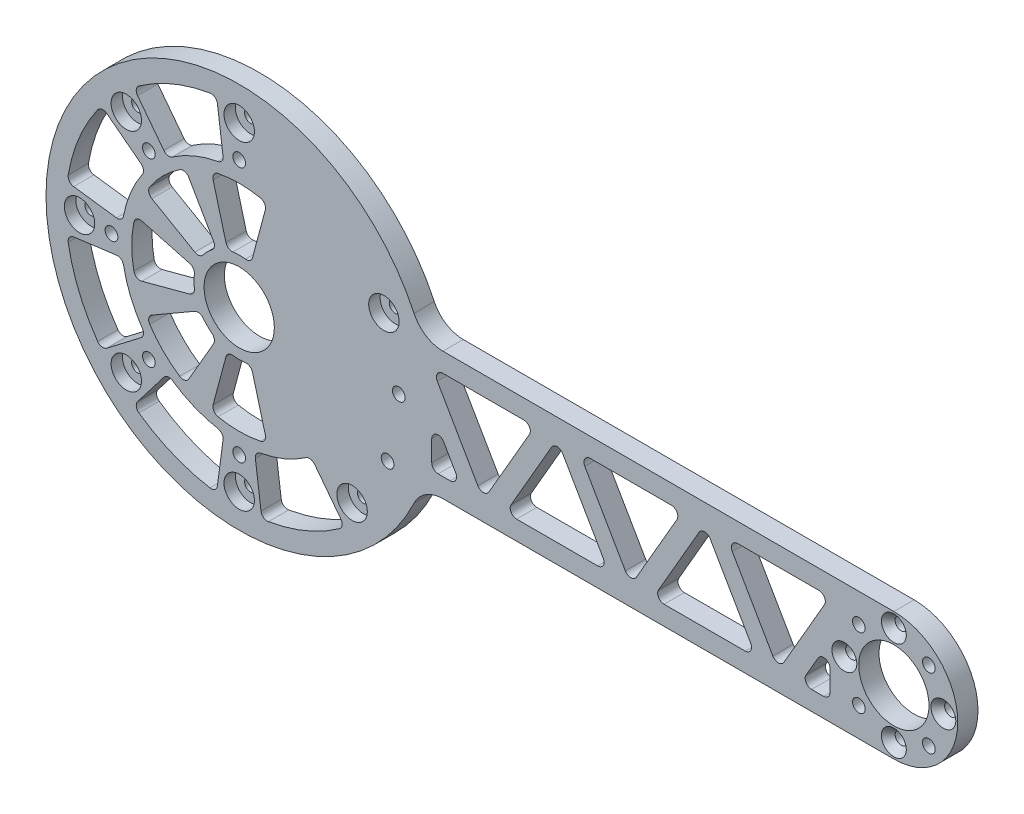
from build123d import *

# Parameters (mm, degrees)
SKETCH1_R                = 11
SKETCH1_R_2              = 1.89865
SKETCH1_R_3              = 1.9939
BOSS_EXTRUDE1_DEPTH      = 6.35
FILLET1_R                = 10
CUT_EXTRUDE1_DEPTH       = 7.35
FILLET2_R                = 2
CUT_EXTRUDE2_DEPTH       = 7.35
FILLET3_R                = 2
CIRPATTERN1_COUNT        = 8
FILLET3_OF_CIRPATTERN1_R = 2
CUT_EXTRUDE4_DEPTH       = 7.35
FILLET5_R                = 2
CIRPATTERN3_COUNT        = 8
FILLET5_OF_CIRPATTERN3_R = 2
CHAMFER1_SIZE            = 2.301024407
CHAMFER1_SIZE2           = 2.00025
CHAMFER1_PART_2_SIZE     = 2.301024407
CHAMFER1_PART_2_SIZE2    = 2.00025
CHAMFER1_PART_3_SIZE     = 2.301024407
CHAMFER1_PART_3_SIZE2    = 2.00025
CHAMFER1_PART_4_SIZE     = 2.301024407
CHAMFER1_PART_4_SIZE2    = 2.00025
SKETCH6_R                = 4.7625
SKETCH6_R_2              = 1.89865
CUT_EXTRUDE5_DEPTH       = 3.571875


with BuildPart() as part:
    # Sketch1 → Boss-Extrude1 (new body)
    with BuildSketch(Plane.XY):
        with BuildLine():
            Line((57.098598932, -20), (205, -20))
            ThreePointArc((205, -20), (225, 0), (205, 20))
            Line((205, 20), (57.098598932, 20))
            ThreePointArc((57.098598932, 20), (-60.5, 0), (57.098598932, -20))
        make_face()
        Circle(SKETCH1_R, mode=Mode.SUBTRACT)
        with Locations((45.315389352, 21.130913087)):
            Circle(SKETCH1_R_2, mode=Mode.SUBTRACT)
        with Locations((49.978847504, 1.454235937)):
            Circle(SKETCH1_R_3, mode=Mode.SUBTRACT)
        with Locations((205, 0)):
            Circle(SKETCH1_R, mode=Mode.SUBTRACT)
        with Locations((46.467376211, -18.460307366)):
            Circle(SKETCH1_R_3, mode=Mode.SUBTRACT)
        with Locations((205, -15.5)):
            Circle(SKETCH1_R_2, mode=Mode.SUBTRACT)
        with Locations((215.960155108, -10.960155108)):
            Circle(SKETCH1_R_3, mode=Mode.SUBTRACT)
        with Locations((189.5, 0)):
            Circle(SKETCH1_R_2, mode=Mode.SUBTRACT)
        with Locations((194.039844892, -10.960155108)):
            Circle(SKETCH1_R_3, mode=Mode.SUBTRACT)
        with Locations((205, 15.5)):
            Circle(SKETCH1_R_2, mode=Mode.SUBTRACT)
        with Locations((194.039844892, 10.960155108)):
            Circle(SKETCH1_R_3, mode=Mode.SUBTRACT)
        with Locations((220.5, 0)):
            Circle(SKETCH1_R_2, mode=Mode.SUBTRACT)
        with Locations((215.960155108, 10.960155108)):
            Circle(SKETCH1_R_3, mode=Mode.SUBTRACT)
        with Locations((0, -40)):
            Circle(SKETCH1_R_3, mode=Mode.SUBTRACT)
        with Locations((0, -50)):
            Circle(SKETCH1_R_2, mode=Mode.SUBTRACT)
        with Locations((-28.284271247, -28.284271247)):
            Circle(SKETCH1_R_3, mode=Mode.SUBTRACT)
        with Locations((-35.355339059, -35.355339059)):
            Circle(SKETCH1_R_2, mode=Mode.SUBTRACT)
        with Locations((-40, 0)):
            Circle(SKETCH1_R_3, mode=Mode.SUBTRACT)
        with Locations((-50, 0)):
            Circle(SKETCH1_R_2, mode=Mode.SUBTRACT)
        with Locations((-28.284271247, 28.284271247)):
            Circle(SKETCH1_R_3, mode=Mode.SUBTRACT)
        with Locations((-35.355339059, 35.355339059)):
            Circle(SKETCH1_R_2, mode=Mode.SUBTRACT)
        with Locations((0, 40)):
            Circle(SKETCH1_R_3, mode=Mode.SUBTRACT)
        with Locations((0, 50)):
            Circle(SKETCH1_R_2, mode=Mode.SUBTRACT)
        with Locations((35.355339059, -35.355339059)):
            Circle(SKETCH1_R_2, mode=Mode.SUBTRACT)
    extrude(amount=BOSS_EXTRUDE1_DEPTH)

    # Fillet1
    fillet1_edges = [part.edges().sort_by_distance(p)[0] for p in [
        (57.098598932, 20, 3.175),
        (57.098598932, -20, 3.175),
    ]]
    fillet(fillet1_edges, radius=FILLET1_R)

    # Sketch2 → Cut-Extrude1 (cut, through all)
    with BuildSketch(Plane.XY.offset(6.35)):
        Polygon((60.292341855, 14), (92.62395693, 14), (76.458149392, -14), align=None)
        Polygon((83.386352623, -14), (99.55216016, 14), (115.717967697, -14), align=None)
        Polygon((106.48036339, 14), (122.646170928, -14), (138.811978465, 14), align=None)
        Polygon((129.574374158, -14), (145.740181695, 14), (161.905989232, -14), align=None)
        Polygon((152.668384925, 14), (168.834192463, -14), (185, 14), align=None)
        Polygon((60.292341855, 2), (60.292341855, -14), (69.529946162, -14), align=None)
        Polygon((185, 2), (185, -14), (175.762395693, -14), align=None)
    extrude(amount=-CUT_EXTRUDE1_DEPTH, mode=Mode.SUBTRACT)

    # Fillet2
    fillet2_edges = [part.edges().sort_by_distance(p)[0] for p in [
        (76.458149392, -14, 3.175),
        (60.292341855, 14, 3.175),
        (92.62395693, 14, 3.175),
        (115.717967697, -14, 3.175),
        (83.386352623, -14, 3.175),
        (99.55216016, 14, 3.175),
        (106.48036339, 14, 3.175),
        (138.811978465, 14, 3.175),
        (122.646170928, -14, 3.175),
        (161.905989232, -14, 3.175),
        (129.574374158, -14, 3.175),
        (145.740181695, 14, 3.175),
        (152.668384925, 14, 3.175),
        (185, 14, 3.175),
        (168.834192463, -14, 3.175),
        (60.292341855, 2, 3.175),
        (69.529946162, -14, 3.175),
        (60.292341855, -14, 3.175),
        (175.762395693, -14, 3.175),
        (185, 2, 3.175),
        (185, -14, 3.175),
    ]]
    fillet(fillet2_edges, radius=FILLET2_R)

    # Sketch3 → Cut-Extrude2 (cut, through all)
    with BuildSketch(Plane.XY.offset(6.35)):
        with BuildLine():
            Line((-32.503404055, 8.709260868), (-13.691998588, 3.668759964))
            ThreePointArc((-13.691998588, 3.668759964), (-14.175, 0), (-13.691998588, -3.668759964))
            Line((-13.691998588, -3.668759964), (-32.503404055, -8.709260868))
            ThreePointArc((-32.503404055, -8.709260868), (-33.65, 0), (-32.503404055, 8.709260868))
        make_face()
    cut_extrude2 = extrude(amount=-CUT_EXTRUDE2_DEPTH, mode=Mode.SUBTRACT)

    # Fillet3
    fillet3_edges = [part.edges().sort_by_distance(p)[0] for p in [
        (-13.691998588, 3.668759964, 3.175),
        (-13.691998588, -3.668759964, 3.175),
        (-32.503404055, -8.709260868, 3.175),
        (-32.503404055, 8.709260868, 3.175),
    ]]
    fillet(fillet3_edges, radius=FILLET3_R)

    # CirPattern1: Cut-Extrude2 ×8 about axis, 3 skipped
    cirpattern1_axis = Axis((0, 0, 0), (0, 0, -1))
    add([cut_extrude2.rotate(cirpattern1_axis, i * 360 / CIRPATTERN1_COUNT) for i in range(1, CIRPATTERN1_COUNT) if i not in (3, 4, 5)], mode=Mode.SUBTRACT)

    # Fillet3 of CirPattern1
    fillet3_of_cirpattern1_edges = [part.edges().sort_by_distance(p)[0] for p in [
        (-7.0875, 12.275910099, 3.175),
        (-12.275910099, 7.0875, 3.175),
        (-29.141754837, 16.825, 3.175),
        (-16.825, 29.141754837, 3.175),
        (3.668759964, 13.691998588, 3.175),
        (-3.668759964, 13.691998588, 3.175),
        (-8.709260868, 32.503404055, 3.175),
        (8.709260868, 32.503404055, 3.175),
        (-3.668759964, -13.691998588, 3.175),
        (3.668759964, -13.691998588, 3.175),
        (8.709260868, -32.503404055, 3.175),
        (-8.709260868, -32.503404055, 3.175),
        (-12.275910099, -7.0875, 3.175),
        (-7.0875, -12.275910099, 3.175),
        (-16.825, -29.141754837, 3.175),
        (-29.141754837, -16.825, 3.175),
    ]]
    fillet(fillet3_of_cirpattern1_edges, radius=FILLET3_OF_CIRPATTERN1_R)

    # Sketch5 → Cut-Extrude4 (cut, through all)
    with BuildSketch(Plane.XY.offset(6.35)):
        with BuildLine():
            Line((-53.860242094, 7.090835392), (-36.50995702, 4.806627029))
            ThreePointArc((-36.50995702, 4.806627029), (-34.021863785, 14.092317397), (-29.215236756, 22.417639623))
            Line((-29.215236756, 22.417639623), (-43.098920211, 33.070964631))
            ThreePointArc((-43.098920211, 33.070964631), (-50.189755604, 20.789277463), (-53.860242094, 7.090835392))
        make_face()
    cut_extrude4 = extrude(amount=-CUT_EXTRUDE4_DEPTH, mode=Mode.SUBTRACT)

    # Fillet5
    fillet5_edges = [part.edges().sort_by_distance(p)[0] for p in [
        (-29.215236756, 22.417639623, 3.175),
        (-36.50995702, 4.806627029, 3.175),
        (-53.860242094, 7.090835392, 3.175),
        (-43.098920211, 33.070964631, 3.175),
    ]]
    fillet(fillet5_edges, radius=FILLET5_R)

    # CirPattern3: Cut-Extrude4 ×8 about axis, 3 skipped
    cirpattern3_axis = Axis((0, 0, 0), (0, 0, -1))
    add([cut_extrude4.rotate(cirpattern3_axis, i * 360 / CIRPATTERN3_COUNT) for i in range(1, CIRPATTERN3_COUNT) if i not in (2, 3, 4)], mode=Mode.SUBTRACT)

    # Fillet5 of CirPattern3
    fillet5_of_cirpattern3_edges = [part.edges().sort_by_distance(p)[0] for p in [
        (-4.806627029, 36.50995702, 3.175),
        (-22.417639623, 29.215236756, 3.175),
        (-33.070964631, 43.098920211, 3.175),
        (-7.090835392, 53.860242094, 3.175),
        (4.806627029, -36.50995702, 3.175),
        (22.417639623, -29.215236756, 3.175),
        (33.070964631, -43.098920211, 3.175),
        (7.090835392, -53.860242094, 3.175),
        (-22.417639623, -29.215236756, 3.175),
        (-4.806627029, -36.50995702, 3.175),
        (-7.090835392, -53.860242094, 3.175),
        (-33.070964631, -43.098920211, 3.175),
        (-36.50995702, -4.806627029, 3.175),
        (-29.215236756, -22.417639623, 3.175),
        (-43.098920211, -33.070964631, 3.175),
        (-53.860242094, -7.090835392, 3.175),
    ]]
    fillet(fillet5_of_cirpattern3_edges, radius=FILLET5_OF_CIRPATTERN3_R)

    # Chamfer1
    chamfer1_edges = [part.edges().sort_by_distance(p)[0] for p in [
        (203.10135, -15.5, 6.35),
    ]]
    chamfer1_side = [part.faces().sort_by_distance(p)[0] for p in [
        (203.10135, -15.5, 3.175),
    ]]
    chamfer(chamfer1_edges, length=CHAMFER1_SIZE, length2=CHAMFER1_SIZE2, reference=chamfer1_side[0])

    # Chamfer1 part 2
    chamfer1_part_2_edges = [part.edges().sort_by_distance(p)[0] for p in [
        (187.60135, 0, 6.35),
    ]]
    chamfer1_part_2_side = [part.faces().sort_by_distance(p)[0] for p in [
        (187.60135, 0, 3.175),
    ]]
    chamfer(chamfer1_part_2_edges, length=CHAMFER1_PART_2_SIZE, length2=CHAMFER1_PART_2_SIZE2, reference=chamfer1_part_2_side[0])

    # Chamfer1 part 3
    chamfer1_part_3_edges = [part.edges().sort_by_distance(p)[0] for p in [
        (203.10135, 15.5, 6.35),
    ]]
    chamfer1_part_3_side = [part.faces().sort_by_distance(p)[0] for p in [
        (203.10135, 15.5, 3.175),
    ]]
    chamfer(chamfer1_part_3_edges, length=CHAMFER1_PART_3_SIZE, length2=CHAMFER1_PART_3_SIZE2, reference=chamfer1_part_3_side[0])

    # Chamfer1 part 4
    chamfer1_part_4_edges = [part.edges().sort_by_distance(p)[0] for p in [
        (218.60135, 0, 6.35),
    ]]
    chamfer1_part_4_side = [part.faces().sort_by_distance(p)[0] for p in [
        (218.60135, 0, 3.175),
    ]]
    chamfer(chamfer1_part_4_edges, length=CHAMFER1_PART_4_SIZE, length2=CHAMFER1_PART_4_SIZE2, reference=chamfer1_part_4_side[0])

    # Sketch6 → Cut-Extrude5 (cut)
    with BuildSketch(Plane.XY.offset(6.35)):
        with Locations((0, 50)):
            Circle(SKETCH6_R)
        with Locations((0, 50)):
            Circle(SKETCH6_R_2, mode=Mode.SUBTRACT)
        with Locations((-35.355339059, 35.355339059)):
            Circle(SKETCH6_R)
        with Locations((-35.355339059, 35.355339059)):
            Circle(SKETCH6_R_2, mode=Mode.SUBTRACT)
        with Locations((-50, 0)):
            Circle(SKETCH6_R)
        with Locations((-50, 0)):
            Circle(SKETCH6_R_2, mode=Mode.SUBTRACT)
        with Locations((-35.355339059, -35.355339059)):
            Circle(SKETCH6_R)
        with Locations((-35.355339059, -35.355339059)):
            Circle(SKETCH6_R_2, mode=Mode.SUBTRACT)
        with Locations((0, -50)):
            Circle(SKETCH6_R)
        with Locations((0, -50)):
            Circle(SKETCH6_R_2, mode=Mode.SUBTRACT)
        with Locations((35.355339059, -35.355339059)):
            Circle(SKETCH6_R)
        with Locations((35.355339059, -35.355339059)):
            Circle(SKETCH6_R_2, mode=Mode.SUBTRACT)
        with Locations((45.315389352, 21.130913087)):
            Circle(SKETCH6_R)
        with Locations((45.315389352, 21.130913087)):
            Circle(SKETCH6_R_2, mode=Mode.SUBTRACT)
    extrude(amount=-CUT_EXTRUDE5_DEPTH, mode=Mode.SUBTRACT)


solid = part.part
